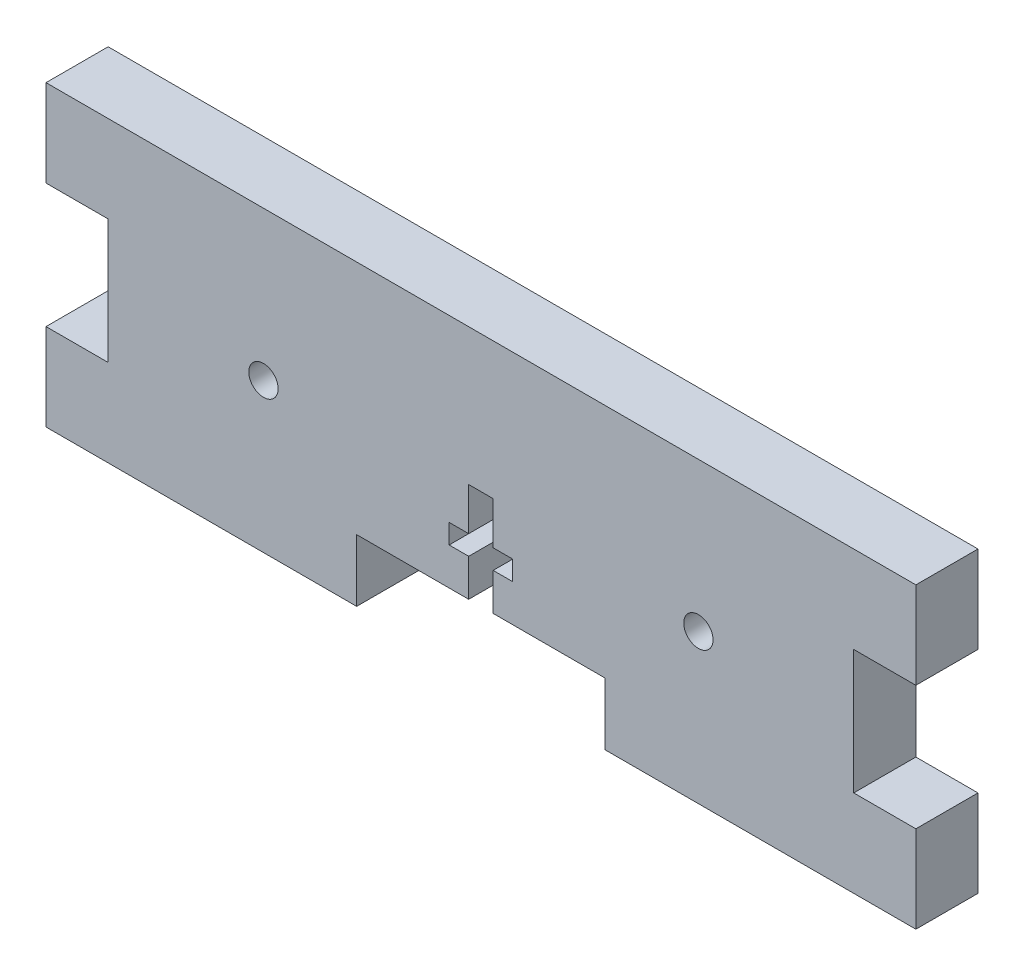
from build123d import *

# Parameters (mm, degrees)
BOSS_EXTRUDE1_DEPTH = 6.35
SKETCH2_R           = 1.5
SKETCH2_W           = 25.4
SKETCH2_H           = 6.35
CUT_EXTRUDE1_DEPTH  = 7.35
CUT_EXTRUDE2_DEPTH  = 7.35


with BuildPart() as part:
    # Sketch1 → Boss-Extrude1 (new body)
    with BuildSketch(Plane.XY):
        Polygon((0, 21.59), (0, 30.48), (88.9, 30.48), (88.9, 21.59), (82.55, 21.59), (82.55, 8.89), (88.9, 8.89), (88.9, 0), (0, 0), (0, 8.89), (6.35, 8.89), (6.35, 21.59), align=None)
    extrude(amount=BOSS_EXTRUDE1_DEPTH)

    # Sketch2 → Cut-Extrude1 (cut, through all)
    with BuildSketch(Plane.XY.offset(6.35)):
        with Locations((22.225, 15.24)):
            Circle(SKETCH2_R)
        with Locations((66.675, 15.24)):
            Circle(SKETCH2_R)
        with Locations((44.45, 3.175)):
            Rectangle(SKETCH2_W, SKETCH2_H)
    extrude(amount=-CUT_EXTRUDE1_DEPTH, mode=Mode.SUBTRACT)

    # Sketch3 → Cut-Extrude2 (cut, through all)
    with BuildSketch(Plane.XY.offset(6.35)):
        Polygon((43.2, 6.35), (45.7, 6.35), (45.7, 10.16), (47.7, 10.16), (47.7, 12.16), (45.7, 12.16), (45.7, 16.51), (43.2, 16.51), (43.2, 12.16), (41.2, 12.16), (41.2, 10.16), (43.2, 10.16), align=None)
    extrude(amount=-CUT_EXTRUDE2_DEPTH, mode=Mode.SUBTRACT)


solid = part.part
